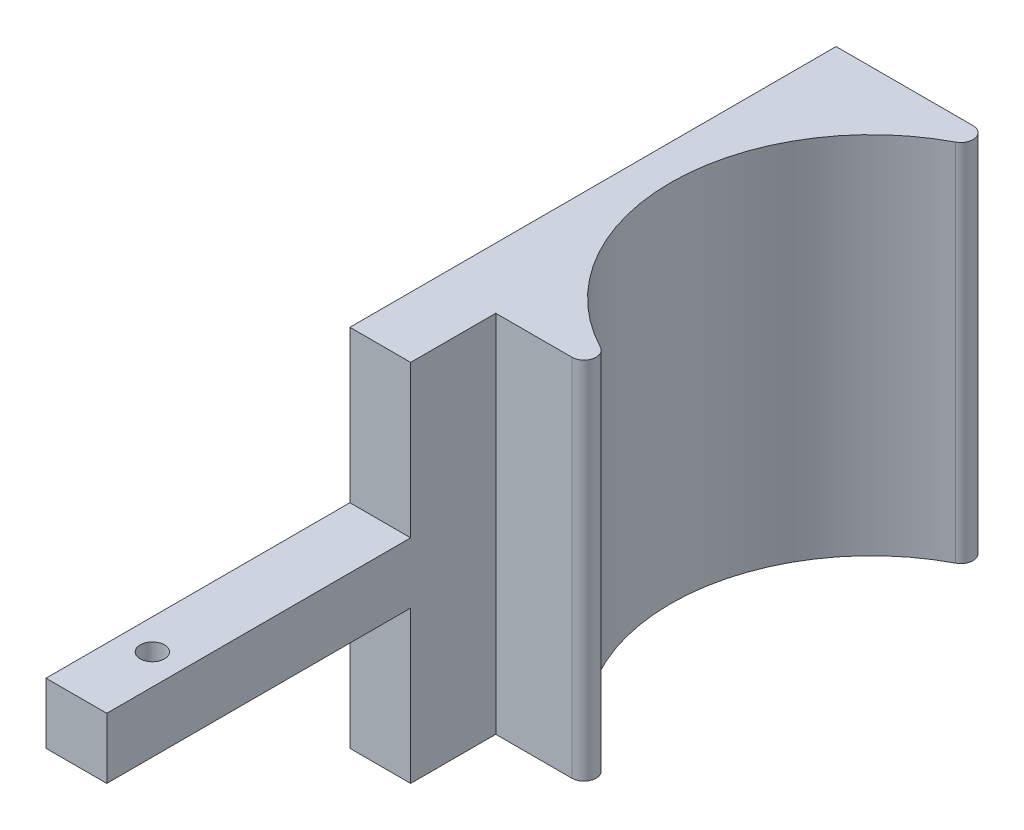
from build123d import *

# Parameters (mm, degrees)
BOSS_EXTRUDE1_DEPTH = 60
SKETCH2_W           = 10
SKETCH2_H           = 50
CUT_EXTRUDE1_DEPTH  = 25
SKETCH3_W           = 10
SKETCH3_H           = 50
CUT_EXTRUDE2_DEPTH  = 25
FILLET1_R           = 2
SKETCH4_R           = 2
CUT_EXTRUDE3_DEPTH  = 25


with BuildPart() as part:
    # Sketch1 → Boss-Extrude1 (new body)
    with BuildSketch(Plane(origin=(0, 0, 0), x_dir=(1, 0, 0), z_dir=(0, 1, 0))):
        with BuildLine():
            Line((-4.271755912, 52.025339674), (24.498929667, 52.025339674))
            ThreePointArc((24.498929667, 52.025339674), (-8.501070333, 19.025339674), (24.498929667, -13.974660326))
            Line((24.498929667, -13.974660326), (-4.271755912, -13.974660326))
            Line((-4.271755912, -13.974660326), (-4.271755912, -77.974660326))
            Line((-4.271755912, -77.974660326), (-14.271755912, -77.974660326))
            Line((-14.271755912, -77.974660326), (-14.271755912, 52.025339674))
            Line((-14.271755912, 52.025339674), (-4.271755912, 52.025339674))
        make_face()
    extrude(amount=BOSS_EXTRUDE1_DEPTH)

    # Sketch2 → Cut-Extrude1 (cut)
    with BuildSketch(Plane(origin=(0, 60, 0), x_dir=(1, 0, 0), z_dir=(0, 1, 0))):
        with Locations((-9.271755912, -52.974660326)):
            Rectangle(SKETCH2_W, SKETCH2_H)
    extrude(amount=-CUT_EXTRUDE1_DEPTH, mode=Mode.SUBTRACT)

    # Sketch3 → Cut-Extrude2 (cut)
    with BuildSketch(Plane.XZ):
        with Locations((-9.271755912, 52.974660326)):
            Rectangle(SKETCH3_W, SKETCH3_H)
    extrude(amount=-CUT_EXTRUDE2_DEPTH, mode=Mode.SUBTRACT)

    # Fillet1
    fillet1_edges = [part.edges().sort_by_distance(p)[0] for p in [
        (24.498929667, 30, -52.025339674),
        (24.498929667, 30, 13.974660326),
    ]]
    fillet(fillet1_edges, radius=FILLET1_R)

    # Sketch4 → Cut-Extrude3 (cut)
    with BuildSketch(Plane(origin=(0, 35, 0), x_dir=(1, 0, 0), z_dir=(0, 1, 0))):
        with Locations((-9.271755912, -65.474660326)):
            Circle(SKETCH4_R)
    extrude(amount=-CUT_EXTRUDE3_DEPTH, mode=Mode.SUBTRACT)


solid = part.part
